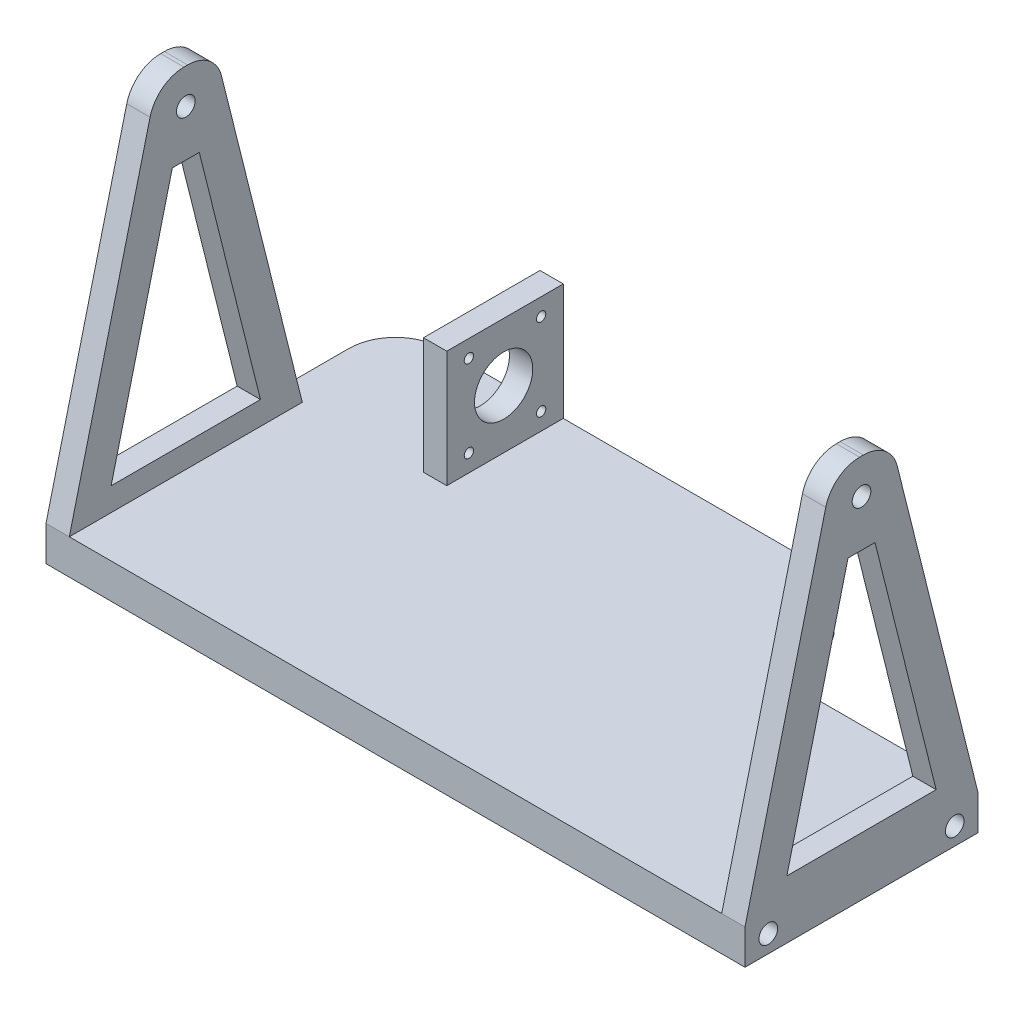
from build123d import *

# Parameters (mm, degrees)
BOSS_EXTRUDE4_DEPTH     = 15
CUT_EXTRUDE2_DEPTH      = 181.900525151
CUT_EXTRUDE2_DEPTH_BACK = 181.900525151
SKETCH9_R               = 4
BOSS_EXTRUDE6_START     = 150
SKETCH10_R              = 4
BOSS_EXTRUDE6_DEPTH     = 10
BOSS_EXTRUDE7_START     = -140
SKETCH12_R              = 4
BOSS_EXTRUDE7_DEPTH     = 10
SKETCH14_W              = 10
SKETCH14_H              = 50
BOSS_EXTRUDE8_DEPTH     = 50
SKETCH15_R              = 2
SKETCH15_R_2            = 12.5
CUT_EXTRUDE3_DEPTH      = 10


with BuildPart() as part:
    # Sketch8 → Boss-Extrude4 (new body)
    with BuildSketch(Plane(origin=(0, 0, 0), x_dir=(1, 0, 0), z_dir=(0, 1, 0))):
        with BuildLine():
            Line((-150, 50), (-150, 80))
            ThreePointArc((-150, 80), (-144.142135624, 94.142135624), (-130, 100))
            Line((-130, 100), (30, 100))
            ThreePointArc((30, 100), (44.142135624, 94.142135624), (50, 80))
            Line((50, 80), (50, 70))
            ThreePointArc((50, 70), (55.857864376, 55.857864376), (70, 50))
            Line((70, 50), (150, 50))
            Line((150, 50), (150, -50))
            Line((150, -50), (-150, -50))
            Line((-150, -50), (-150, 50))
        make_face()
    extrude(amount=BOSS_EXTRUDE4_DEPTH)

    # Sketch9 → Cut-Extrude2 (cut, two sides: drawn at the far end of the back side and taken through both)
    with BuildSketch(Plane(origin=(0, 0, 0), x_dir=(0, 0, -1), z_dir=(1, 0, 0)).offset(-CUT_EXTRUDE2_DEPTH_BACK)):
        with Locations((-40, 7.5)):
            Circle(SKETCH9_R)
        with Locations((40, 7.5)):
            Circle(SKETCH9_R)
    extrude(amount=CUT_EXTRUDE2_DEPTH + CUT_EXTRUDE2_DEPTH_BACK, mode=Mode.SUBTRACT)

    # Sketch10 → Boss-Extrude6 (add)
    with BuildSketch(Plane(origin=(0, 0, 0), x_dir=(0, 0, -1), z_dir=(1, 0, 0)).offset(BOSS_EXTRUDE6_START)):
        with BuildLine():
            Line((-50, 15), (50, 15))
            Line((50, 15), (15.340491406, 153.638034376))
            ThreePointArc((15.340491406, 153.638034376), (10.019537045, 161.82308157), (0.788353904, 165))
            Line((0.788353904, 165), (-0.788353904, 165))
            ThreePointArc((-0.788353904, 165), (-10.019537045, 161.82308157), (-15.340491406, 153.638034376))
            Line((-15.340491406, 153.638034376), (-50, 15))
        make_face()
        with Locations((0, 150)):
            Circle(SKETCH10_R, mode=Mode.SUBTRACT)
        Polygon((-32.038353904, 25), (32.038353904, 25), (5.788353904, 130), (-5.788353904, 130), align=None, mode=Mode.SUBTRACT)
    extrude(amount=-BOSS_EXTRUDE6_DEPTH)

    # Sketch12 → Boss-Extrude7 (add)
    with BuildSketch(Plane(origin=(0, 0, 0), x_dir=(0, 0, -1), z_dir=(1, 0, 0)).offset(BOSS_EXTRUDE7_START)):
        with BuildLine():
            Line((-50, 15), (50, 15))
            Line((50, 15), (15.340491406, 153.638034376))
            ThreePointArc((15.340491406, 153.638034376), (10.019537045, 161.82308157), (0.788353904, 165))
            Line((0.788353904, 165), (-0.788353904, 165))
            ThreePointArc((-0.788353904, 165), (-10.019537045, 161.82308157), (-15.340491406, 153.638034376))
            Line((-15.340491406, 153.638034376), (-50, 15))
        make_face()
        with Locations((0, 150)):
            Circle(SKETCH12_R, mode=Mode.SUBTRACT)
        Polygon((-32.038353904, 25), (32.038353904, 25), (5.788353904, 130), (-5.788353904, 130), align=None, mode=Mode.SUBTRACT)
    extrude(amount=-BOSS_EXTRUDE7_DEPTH)

    # Sketch14 → Boss-Extrude8 (add)
    with BuildSketch(Plane(origin=(0, 15, 0), x_dir=(1, 0, 0), z_dir=(0, 1, 0))):
        with Locations((-83, 75)):
            Rectangle(SKETCH14_W, SKETCH14_H)
    extrude(amount=BOSS_EXTRUDE8_DEPTH)

    # Sketch15 → Cut-Extrude3 (cut)
    with BuildSketch(Plane.ZY.offset(88)):
        with Locations((-90.5, 57.610296458)):
            Circle(SKETCH15_R)
        with Locations((-59.5, 57.610296458)):
            Circle(SKETCH15_R)
        with Locations((-90.5, 22.389703542)):
            Circle(SKETCH15_R)
        with Locations((-59.5, 22.389703542)):
            Circle(SKETCH15_R)
        with Locations((-74.409733022, 40)):
            Circle(SKETCH15_R_2)
    extrude(amount=-CUT_EXTRUDE3_DEPTH, mode=Mode.SUBTRACT)


solid = part.part
